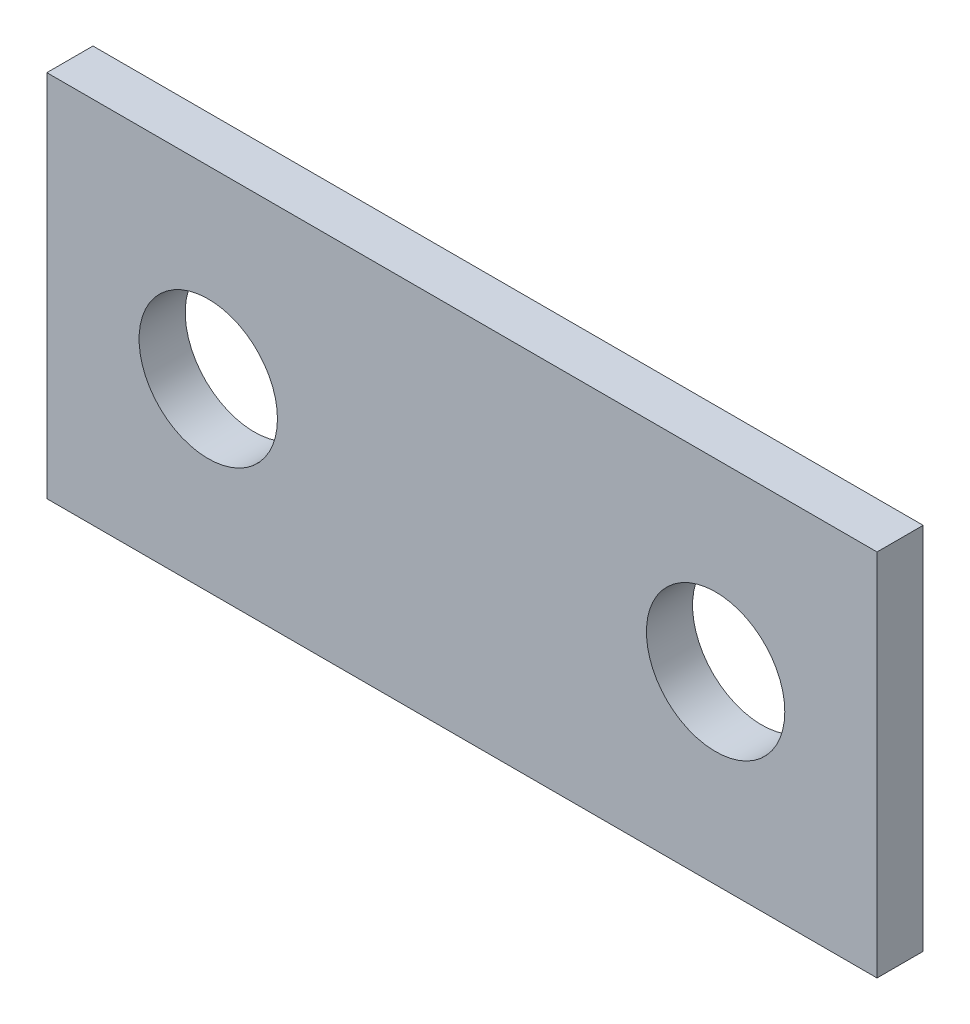
from build123d import *

# Parameters (mm, degrees)
SKETCH1_W           = 57.15
SKETCH1_H           = 25.4
SKETCH1_R           = 4.7625
BOSS_EXTRUDE1_DEPTH = 3.175


with BuildPart() as part:
    # Sketch1 → Boss-Extrude1 (new body)
    with BuildSketch(Plane.XY):
        Rectangle(SKETCH1_W, SKETCH1_H)
        with Locations((-17.4625, 0)):
            Circle(SKETCH1_R, mode=Mode.SUBTRACT)
        with Locations((17.4625, 0)):
            Circle(SKETCH1_R, mode=Mode.SUBTRACT)
    extrude(amount=BOSS_EXTRUDE1_DEPTH)


solid = part.part
